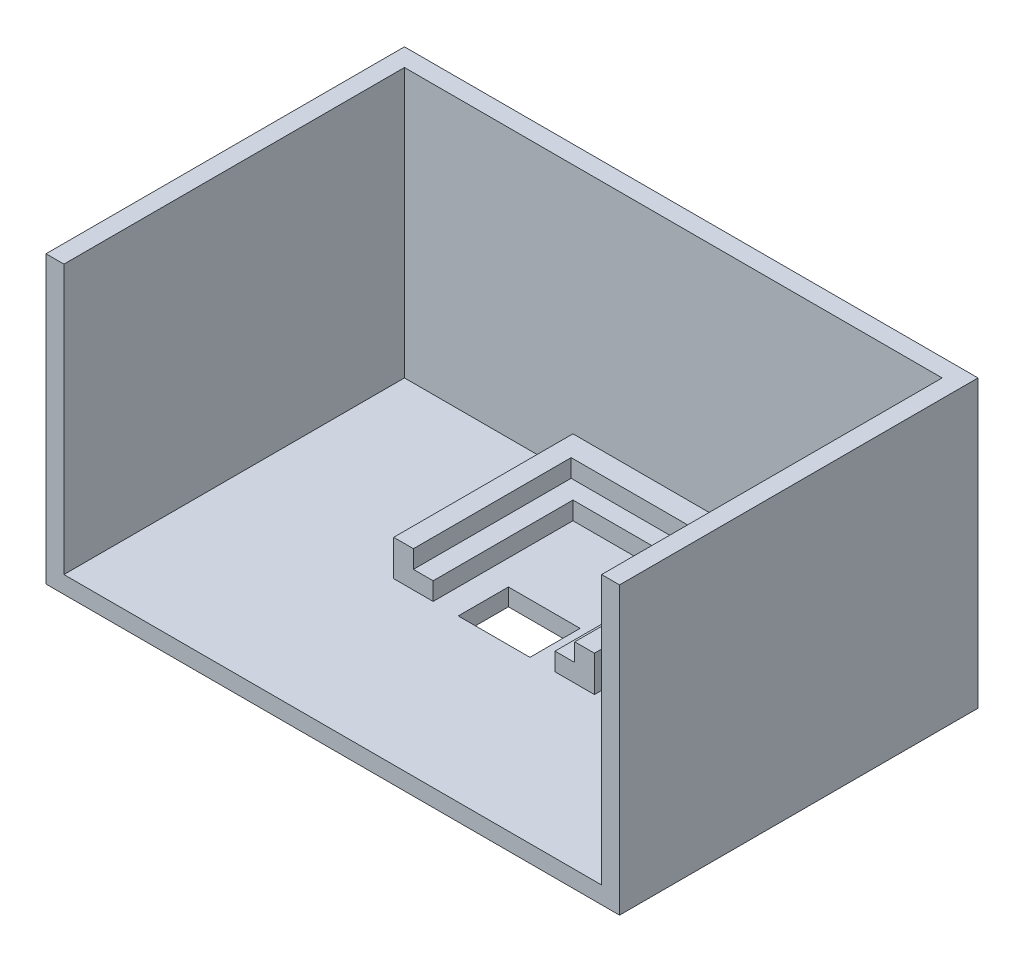
from build123d import *

# Parameters (mm, degrees)
SKETCH1_W           = 80
SKETCH1_H           = 50
BOSS_EXTRUDE1_DEPTH = 2.5
SKETCH2_W           = 80
SKETCH2_H           = 50
SKETCH2_W_2         = 75
SKETCH2_H_2         = 45
BOSS_EXTRUDE2_DEPTH = 37.5
CUT_EXTRUDE2_DEPTH  = 2.5
SKETCH11_W          = 80
SKETCH11_H          = 50
CUT_EXTRUDE10_DEPTH = 0.1
BOSS_EXTRUDE4_DEPTH = 5
SKETCH8_W           = 10
SKETCH8_H           = 7
CUT_EXTRUDE14_DEPTH = 10
SKETCH15_W          = 75
SKETCH15_H          = 37.5
CUT_EXTRUDE15_DEPTH = 10
SKETCH14_W          = 22.5
SKETCH14_H          = 22
CUT_EXTRUDE16_DEPTH = 2.5


with BuildPart() as part:
    # Sketch1 → Boss-Extrude1 (new body)
    with BuildSketch(Plane(origin=(0, 0, 0), x_dir=(1, 0, 0), z_dir=(0, 1, 0))):
        with Locations((-26.709650323, 17.072563556)):
            Rectangle(SKETCH1_W, SKETCH1_H)
    extrude(amount=BOSS_EXTRUDE1_DEPTH)

    # Sketch2 → Boss-Extrude2 (add)
    with BuildSketch(Plane(origin=(0, 2.5, 0), x_dir=(1, 0, 0), z_dir=(0, 1, 0))):
        with Locations((-26.709650323, 17.072563556)):
            Rectangle(SKETCH2_W, SKETCH2_H)
        with Locations((-26.709650323, 17.072563556)):
            Rectangle(SKETCH2_W_2, SKETCH2_H_2, mode=Mode.SUBTRACT)
    extrude(amount=BOSS_EXTRUDE2_DEPTH)

    # Sketch5 → Cut-Extrude2 (cut)
    with BuildSketch(Plane.XY.offset(7.927436444)):
        with BuildLine():
            Line((-20.404890216, 2.5), (-33.014410429, 2.5))
            ThreePointArc((-33.014410429, 2.5), (-26.709650323, 29), (-20.404890216, 2.5))
        make_face()
    extrude(amount=-CUT_EXTRUDE2_DEPTH, mode=Mode.SUBTRACT)

    # Sketch11 → Cut-Extrude10 (cut)
    with BuildSketch(Plane(origin=(0, 0, 0), x_dir=(-1, 0, 0), z_dir=(0, -1, 0))):
        with Locations((26.709650323, 17.072563556)):
            Rectangle(SKETCH11_W, SKETCH11_H)
    extrude(amount=-CUT_EXTRUDE10_DEPTH, mode=Mode.SUBTRACT)

    # Sketch6 → Boss-Extrude4 (add)
    with BuildSketch(Plane(origin=(0, 2.5, 0), x_dir=(1, 0, 0), z_dir=(0, 1, 0))):
        Polygon((-40.709650323, 39.572563556), (-12.709650323, 39.572563556), (-12.709650323, 14.572563556), (-18.209650323, 14.572563556), (-18.209650323, 34.072563556), (-35.209650323, 34.072563556), (-35.209650323, 14.572563556), (-40.709650323, 14.572563556), align=None)
    extrude(amount=BOSS_EXTRUDE4_DEPTH)

    # Sketch8 → Cut-Extrude14 (cut)
    with BuildSketch(Plane(origin=(0, 2.5, 0), x_dir=(1, 0, 0), z_dir=(0, 1, 0))):
        with Locations((-26.709650323, 18.072563556)):
            Rectangle(SKETCH8_W, SKETCH8_H)
    extrude(amount=-CUT_EXTRUDE14_DEPTH, mode=Mode.SUBTRACT)

    # Sketch15 → Cut-Extrude15 (cut)
    with BuildSketch(Plane(origin=(0, 0, 5.427436444), x_dir=(-1, 0, 0), z_dir=(0, 0, -1))):
        with Locations((26.709650323, 21.25)):
            Rectangle(SKETCH15_W, SKETCH15_H)
    extrude(amount=-CUT_EXTRUDE15_DEPTH, mode=Mode.SUBTRACT)

    # Sketch14 → Cut-Extrude16 (cut)
    with BuildSketch(Plane(origin=(0, 7.5, 0), x_dir=(1, 0, 0), z_dir=(0, 1, 0))):
        with Locations((-26.709650323, 25.572563556)):
            Rectangle(SKETCH14_W, SKETCH14_H)
    extrude(amount=-CUT_EXTRUDE16_DEPTH, mode=Mode.SUBTRACT)


solid = part.part
